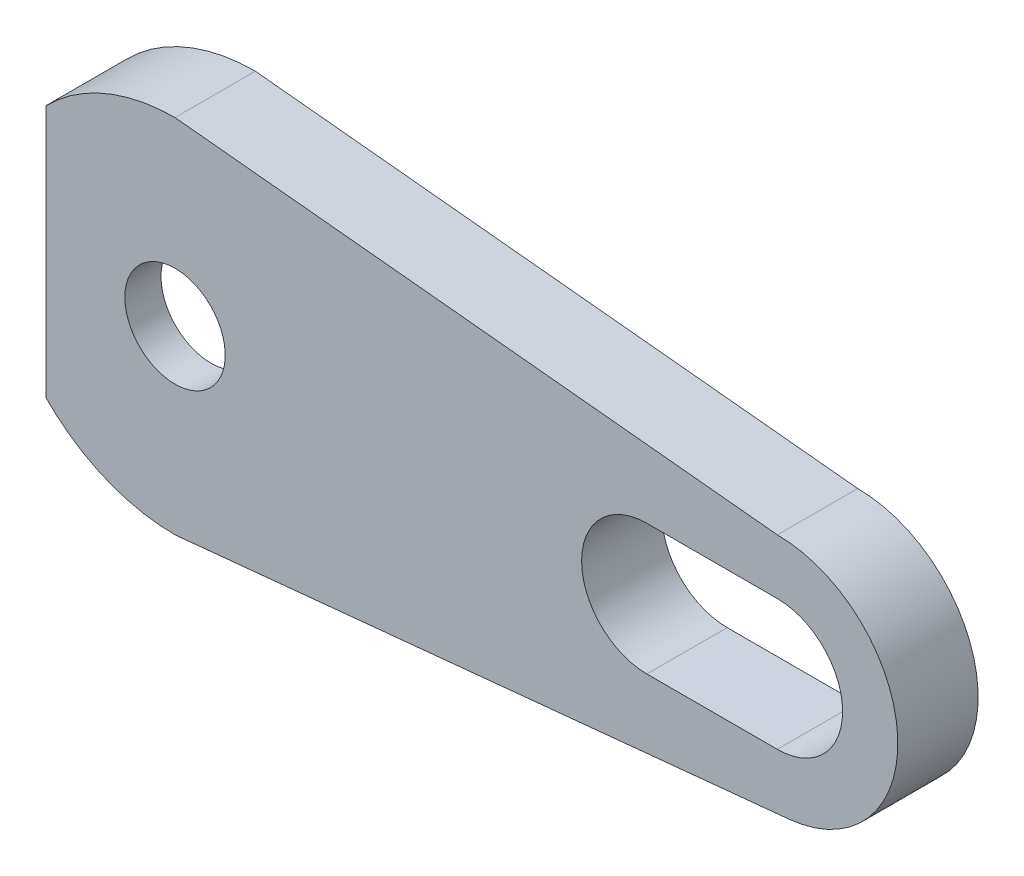
from build123d import *

# Parameters (mm, degrees)
MAIN_DEPTH          = 4
ESQUISSE2_R         = 2.5
BOSS_EXTRUDE1_DEPTH = 1.8


with BuildPart() as part:
    # Esquisse1 → Main (new body)
    with BuildSketch(Plane.XY):
        with BuildLine():
            Line((-4.375785644, 4.25), (-6.426543071, 6.300757427))
            ThreePointArc((-6.426543071, 6.300757427), (-3.48519606, 8.297795395), (0, 9))
            Line((0, 9), (30, 6))
            ThreePointArc((30, 6), (35.9926952, 0.295980134), (30.591239576, -5.970798587))
            Line((30.591239576, -5.970798587), (0, -9))
            ThreePointArc((0, -9), (-3.48519606, -8.297795395), (-6.426543071, -6.300757427))
            Line((-6.426543071, -6.300757427), (-4.375785644, -4.25))
            ThreePointArc((-4.375785644, -4.25), (0, -6.1), (4.375785644, -4.25))
            Line((4.375785644, -4.25), (17.31559729, -2.78215714))
            ThreePointArc((17.31559729, -2.78215714), (19.8, 0), (17.31559729, 2.78215714))
            Line((17.31559729, 2.78215714), (4.375785644, 4.25))
            ThreePointArc((4.375785644, 4.25), (0, 6.1), (-4.375785644, 4.25))
        make_face()
        with BuildLine():
            Line((23.5, 3.25), (30, 3.25))
            ThreePointArc((30, 3.25), (33.25, 0), (30, -3.25))
            Line((30, -3.25), (23.5, -3.25))
            ThreePointArc((23.5, -3.25), (20.25, 0), (23.5, 3.25))
        make_face(mode=Mode.SUBTRACT)
    extrude(amount=MAIN_DEPTH)

    # Esquisse2 → Boss-Extrude1 (add)
    with BuildSketch(Plane(origin=(0, 0, 4), x_dir=(-1, 0, 0), z_dir=(0, 0, -1))):
        with BuildLine():
            Line((0, -9), (-13.303143835, -7.682697966))
            ThreePointArc((-13.303143835, -7.682697966), (-20.25000193, -0.006506175), (-13.303143835, 7.669685617))
            Line((-13.303143835, 7.669685617), (0, 9))
            ThreePointArc((0, 9), (3.48519606, 8.297795395), (6.426543071, 6.300757427))
            Line((6.426543071, 6.300757427), (6.426543071, -6.300757427))
            ThreePointArc((6.426543071, -6.300757427), (3.48519606, -8.297795395), (0, -9))
        make_face()
        Circle(ESQUISSE2_R, mode=Mode.SUBTRACT)
    extrude(amount=BOSS_EXTRUDE1_DEPTH)


solid = part.part
